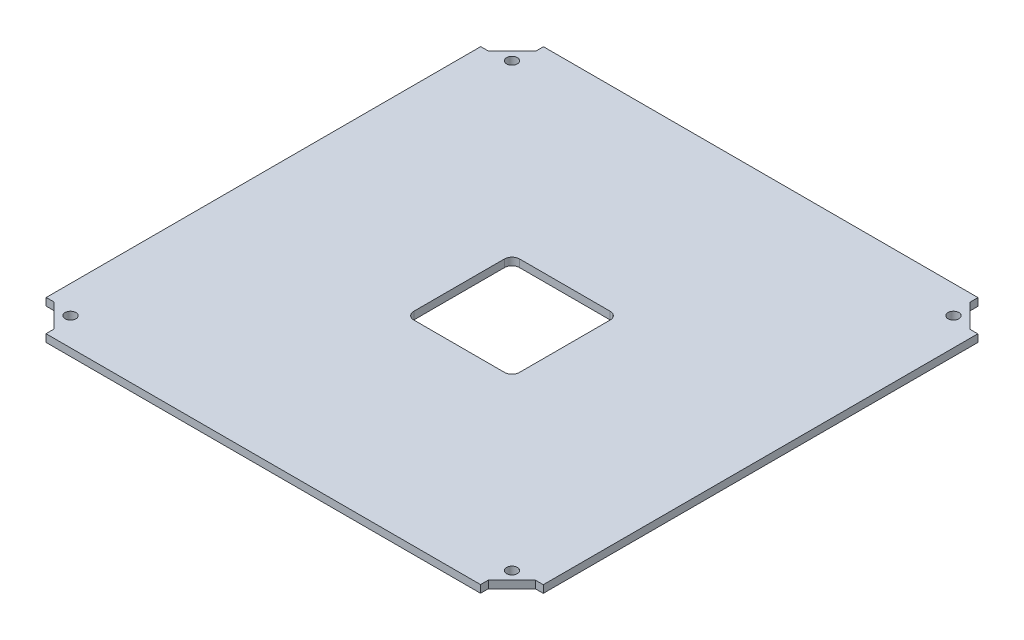
from build123d import *

# Parameters (mm, degrees)
BOSS_EXTRUDE1_DEPTH = 3.175
CUT_EXTRUDE1_REACH  = 5.175
SKETCH3_R           = 2.286
CUT_EXTRUDE2_REACH  = 5.175
SKETCH5_W           = 44.45
SKETCH5_H           = 44.45
FILLET1_R           = 3.175


with BuildPart() as part:
    # Sketch1 → Boss-Extrude1 (new body)
    with BuildSketch(Plane(origin=(0, 0, 0), x_dir=(1, 0, 0), z_dir=(0, 1, 0))):
        Polygon((-91.233267746, 104.4575), (-91.233267746, 101.1555), (-101.1555, 91.321365209), (-104.4575, 91.321365209), (-104.4575, -91.233267746), (-101.1555, -91.233267746), (-91.321365209, -101.1555), (-91.321365209, -104.4575), (91.233267746, -104.4575), (91.233267746, -101.1555), (101.1555, -91.321365209), (104.4575, -91.321365209), (104.4575, 91.233267746), (101.1555, 91.233267746), (91.321365209, 101.1555), (91.321365209, 104.4575), align=None)
    extrude(amount=BOSS_EXTRUDE1_DEPTH)

    # Sketch3 → Cut-Extrude1 (cut, up to next)
    with BuildSketch(Plane(origin=(0, 3.175, 0), x_dir=(1, 0, 0), z_dir=(0, 1, 0)), mode=Mode.PRIVATE) as cut_extrude1_sk1:
        with Locations((-92.73413, 92.73413)):
            Circle(SKETCH3_R)
    cut_extrude1_tool1 = extrude(cut_extrude1_sk1.sketch, amount=-CUT_EXTRUDE1_REACH, mode=Mode.PRIVATE) & part.part
    add(cut_extrude1_tool1.solids().sort_by_distance((-92.73413, 3.175, -92.73413))[0], mode=Mode.SUBTRACT)
    # Sketch3 → Cut-Extrude1 (cut, up to next)
    with BuildSketch(Plane(origin=(0, 3.175, 0), x_dir=(1, 0, 0), z_dir=(0, 1, 0)), mode=Mode.PRIVATE) as cut_extrude1_sk2:
        with Locations((92.73413, 92.73413)):
            Circle(SKETCH3_R)
    cut_extrude1_tool2 = extrude(cut_extrude1_sk2.sketch, amount=-CUT_EXTRUDE1_REACH, mode=Mode.PRIVATE) & part.part
    add(cut_extrude1_tool2.solids().sort_by_distance((92.73413, 3.175, -92.73413))[0], mode=Mode.SUBTRACT)
    # Sketch3 → Cut-Extrude1 (cut, up to next)
    with BuildSketch(Plane(origin=(0, 3.175, 0), x_dir=(1, 0, 0), z_dir=(0, 1, 0)), mode=Mode.PRIVATE) as cut_extrude1_sk3:
        with Locations((92.73413, -92.73413)):
            Circle(SKETCH3_R)
    cut_extrude1_tool3 = extrude(cut_extrude1_sk3.sketch, amount=-CUT_EXTRUDE1_REACH, mode=Mode.PRIVATE) & part.part
    add(cut_extrude1_tool3.solids().sort_by_distance((92.73413, 3.175, 92.73413))[0], mode=Mode.SUBTRACT)
    # Sketch3 → Cut-Extrude1 (cut, up to next)
    with BuildSketch(Plane(origin=(0, 3.175, 0), x_dir=(1, 0, 0), z_dir=(0, 1, 0)), mode=Mode.PRIVATE) as cut_extrude1_sk4:
        with Locations((-92.73413, -92.73413)):
            Circle(SKETCH3_R)
    cut_extrude1_tool4 = extrude(cut_extrude1_sk4.sketch, amount=-CUT_EXTRUDE1_REACH, mode=Mode.PRIVATE) & part.part
    add(cut_extrude1_tool4.solids().sort_by_distance((-92.73413, 3.175, 92.73413))[0], mode=Mode.SUBTRACT)

    # Sketch5 → Cut-Extrude2 (cut, up to next)
    with BuildSketch(Plane(origin=(0, 3.175, 0), x_dir=(1, 0, 0), z_dir=(0, 1, 0)), mode=Mode.PRIVATE) as cut_extrude2_sk1:
        Rectangle(SKETCH5_W, SKETCH5_H)
    cut_extrude2_tool1 = extrude(cut_extrude2_sk1.sketch, amount=-CUT_EXTRUDE2_REACH, mode=Mode.PRIVATE) & part.part
    add(cut_extrude2_tool1.solids().sort_by_distance((0, 3.175, 0))[0], mode=Mode.SUBTRACT)

    # Fillet1
    fillet1_edges = [part.edges().sort_by_distance(p)[0] for p in [
        (-22.225, 1.5875, 22.225),
        (-22.225, 1.5875, -22.225),
        (22.225, 1.5875, -22.225),
        (22.225, 1.5875, 22.225),
    ]]
    fillet(fillet1_edges, radius=FILLET1_R)


solid = part.part
